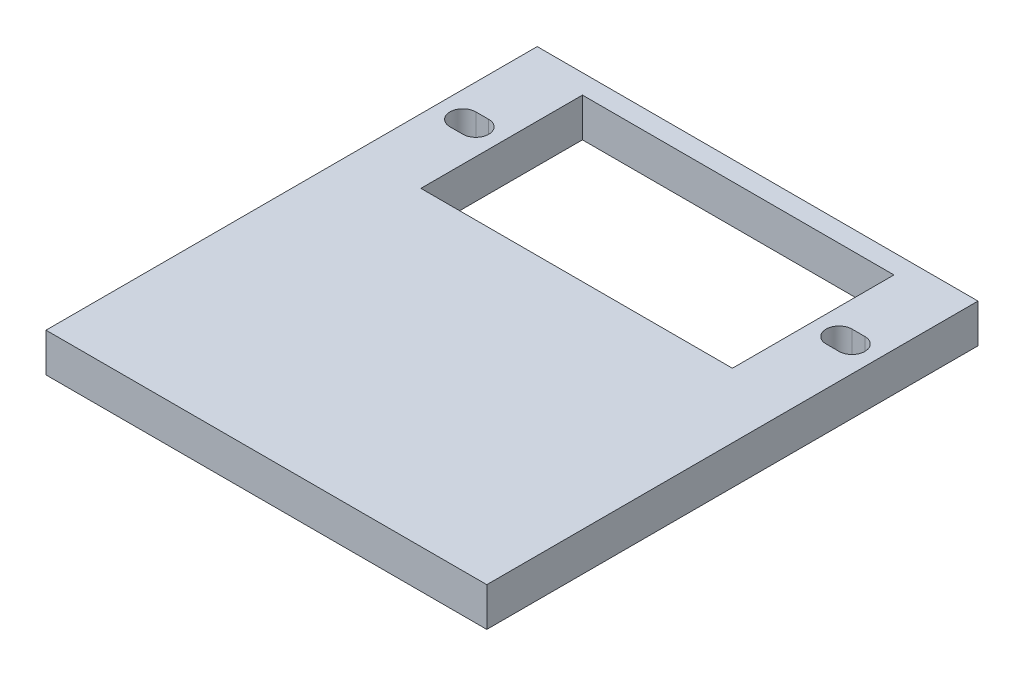
from build123d import *

# Parameters (mm, degrees)
BOSS_EXTRU_1_DEPTH = 3


with BuildPart() as part:
    # Esquisse1 → Boss.-Extru.1 (new body)
    with BuildSketch(Plane(origin=(0, 0, 0), x_dir=(1, 0, 0), z_dir=(0, 1, 0))):
        Polygon((-12.05, 36.5), (0, 36.5), (0, 38), (-17.05, 38), (-17.05, 0), (0, 0), (0, 24), (-12.05, 24), align=None)
        with BuildLine():
            ThreePointArc((-15.05, 29.25), (-16.05, 30.25), (-15.05, 31.25))
            Line((-15.05, 31.25), (-14.05, 31.25))
            ThreePointArc((-14.05, 31.25), (-13.05, 30.25), (-14.05, 29.25))
            Line((-14.05, 29.25), (-15.05, 29.25))
        make_face(mode=Mode.SUBTRACT)
    boss_extru_1 = extrude(amount=BOSS_EXTRU_1_DEPTH)

    # Symétrie1: Boss.-Extru.1 across plane
    add(boss_extru_1.mirror(Plane(origin=(0, 3, 0), x_dir=(0, 0, 1), z_dir=(-1, 0, 0))))


solid = part.part
